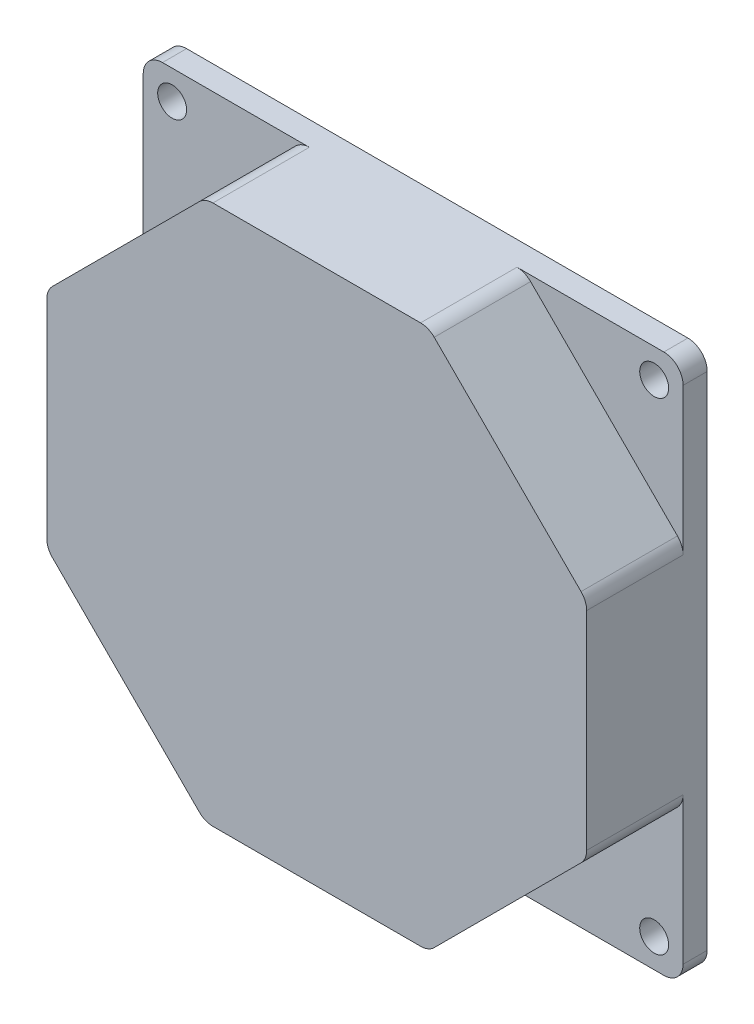
from build123d import *

# Parameters (mm, degrees)
SKETCH1_R           = 1.5
BOSS_EXTRUDE1_DEPTH = 2.5
BOSS_EXTRUDE2_DEPTH = 10
FILLET1_R           = 2
SKETCH3_R           = 2.5
CUT_EXTRUDE1_DEPTH  = 5
SKETCH4_R           = 5
SKETCH4_R_2         = 4.5
CUT_EXTRUDE2_DEPTH  = 0.5
SKETCH5_W           = 10
SKETCH5_H           = 6
SKETCH5_R           = 0.5
CUT_EXTRUDE3_DEPTH  = 5


with BuildPart() as part:
    # Sketch1 → Boss-Extrude1 (new body)
    with BuildSketch(Plane.XY):
        with BuildLine():
            Line((-26, 28), (26, 28))
            ThreePointArc((26, 28), (27.414213562, 27.414213562), (28, 26))
            Line((28, 26), (28, -26))
            ThreePointArc((28, -26), (27.414213562, -27.414213562), (26, -28))
            Line((26, -28), (-26, -28))
            ThreePointArc((-26, -28), (-27.414213562, -27.414213562), (-28, -26))
            Line((-28, -26), (-28, 26))
            ThreePointArc((-28, 26), (-27.414213562, 27.414213562), (-26, 28))
        make_face()
        with Locations((-25, 25)):
            Circle(SKETCH1_R, mode=Mode.SUBTRACT)
        with Locations((25, 25)):
            Circle(SKETCH1_R, mode=Mode.SUBTRACT)
        with Locations((25, -25)):
            Circle(SKETCH1_R, mode=Mode.SUBTRACT)
        with Locations((-25, -25)):
            Circle(SKETCH1_R, mode=Mode.SUBTRACT)
    extrude(amount=BOSS_EXTRUDE1_DEPTH)

    # Sketch2 → Boss-Extrude2 (add)
    with BuildSketch(Plane.XY.offset(2.5)):
        Polygon((-11.597979746, -28), (11.597979746, -28), (28, -11.597979746), (28, 11.597979746), (11.597979746, 28), (-11.597979746, 28), (-28, 11.597979746), (-28, -11.597979746), align=None)
    extrude(amount=BOSS_EXTRUDE2_DEPTH)

    # Fillet1
    fillet1_edges = [part.edges().sort_by_distance(p)[0] for p in [
        (11.597979746, -28, 7.5),
        (28, -11.597979746, 7.5),
        (28, 11.597979746, 7.5),
        (11.597979746, 28, 7.5),
        (-11.597979746, 28, 7.5),
        (-28, 11.597979746, 7.5),
        (-28, -11.597979746, 7.5),
        (-11.597979746, -28, 7.5),
    ]]
    fillet(fillet1_edges, radius=FILLET1_R)

    # Sketch3 → Cut-Extrude1 (cut)
    with BuildSketch(Plane(origin=(0, 0, 0), x_dir=(-1, 0, 0), z_dir=(0, 0, -1))):
        Circle(SKETCH3_R)
    extrude(amount=-CUT_EXTRUDE1_DEPTH, mode=Mode.SUBTRACT)

    # Sketch4 → Cut-Extrude2 (cut)
    with BuildSketch(Plane(origin=(0, 0, 0), x_dir=(-1, 0, 0), z_dir=(0, 0, -1))):
        Circle(SKETCH4_R)
        Circle(SKETCH4_R_2, mode=Mode.SUBTRACT)
    extrude(amount=-CUT_EXTRUDE2_DEPTH, mode=Mode.SUBTRACT)

    # Sketch5 → Cut-Extrude3 (cut)
    with BuildSketch(Plane.XZ.offset(28)):
        with Locations((0, 7.5)):
            Rectangle(SKETCH5_W, SKETCH5_H)
        with Locations((-3, 7.5)):
            Circle(SKETCH5_R, mode=Mode.SUBTRACT)
        with Locations((-1, 7.5)):
            Circle(SKETCH5_R, mode=Mode.SUBTRACT)
        with Locations((1, 7.5)):
            Circle(SKETCH5_R, mode=Mode.SUBTRACT)
        with Locations((3, 7.5)):
            Circle(SKETCH5_R, mode=Mode.SUBTRACT)
    extrude(amount=-CUT_EXTRUDE3_DEPTH, mode=Mode.SUBTRACT)


solid = part.part
